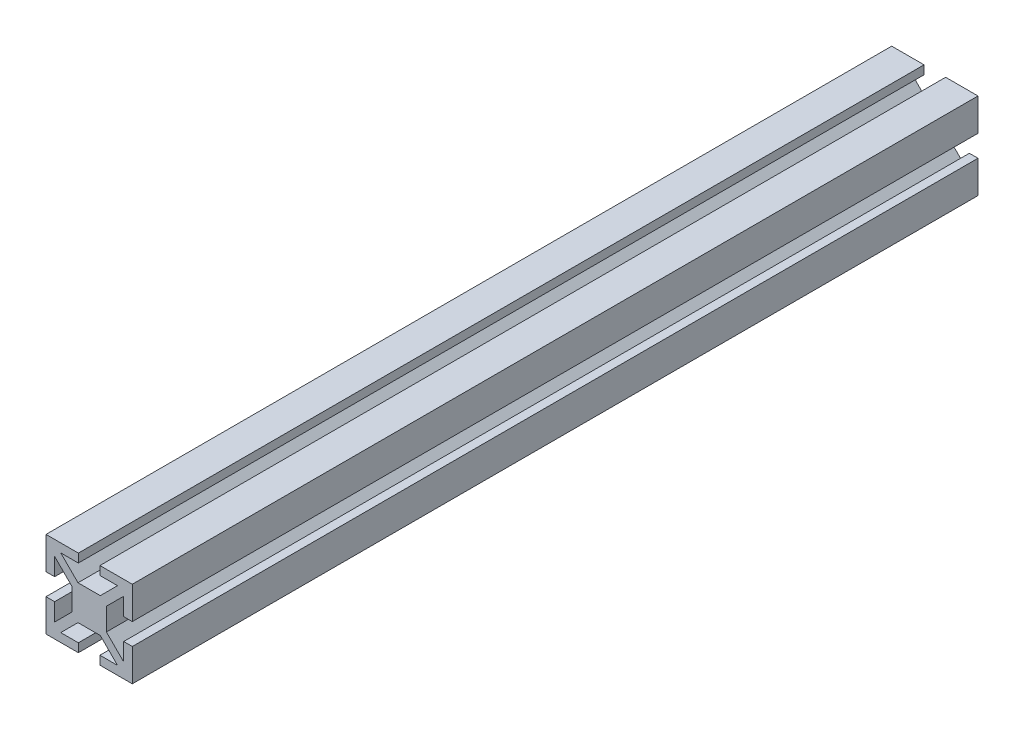
from build123d import *

# Parameters (mm, degrees)
BOSS_EXTRUDE1_DEPTH = 98
SKETCH2_R           = 2.5
CUT_EXTRUDE1_DEPTH  = 10


with BuildPart() as part:
    # Sketch1 → Boss-Extrude1 (new body, symmetric)
    with BuildSketch(Plane.XY):
        Polygon((-2.585786438, 4), (2.585786438, 4), (6.585786438, 8), (2.5, 8), (2.5, 10), (10, 10), (10, 2.5), (8, 2.5), (8, 6.585786438), (4, 2.585786438), (4, -2.585786438), (8, -6.585786438), (8, -2.5), (10, -2.5), (10, -10), (2.5, -10), (2.5, -8), (6.585786438, -8), (2.585786438, -4), (-2.585786438, -4), (-6.585786438, -8), (-2.5, -8), (-2.5, -10), (-10, -10), (-10, -2.5), (-8, -2.5), (-8, -6.585786438), (-4, -2.585786438), (-4, 2.585786438), (-8, 6.585786438), (-8, 2.5), (-10, 2.5), (-10, 10), (-2.5, 10), (-2.5, 8), (-6.585786438, 8), align=None)
    extrude(amount=BOSS_EXTRUDE1_DEPTH, both=True)

    # Sketch2 → Cut-Extrude1 (cut)
    with BuildSketch(Plane(origin=(4, 0, 0), x_dir=(0, 0, -1), z_dir=(1, 0, 0))):
        with Locations((88, 0)):
            Circle(SKETCH2_R)
    extrude(amount=-CUT_EXTRUDE1_DEPTH, mode=Mode.SUBTRACT)


solid = part.part
